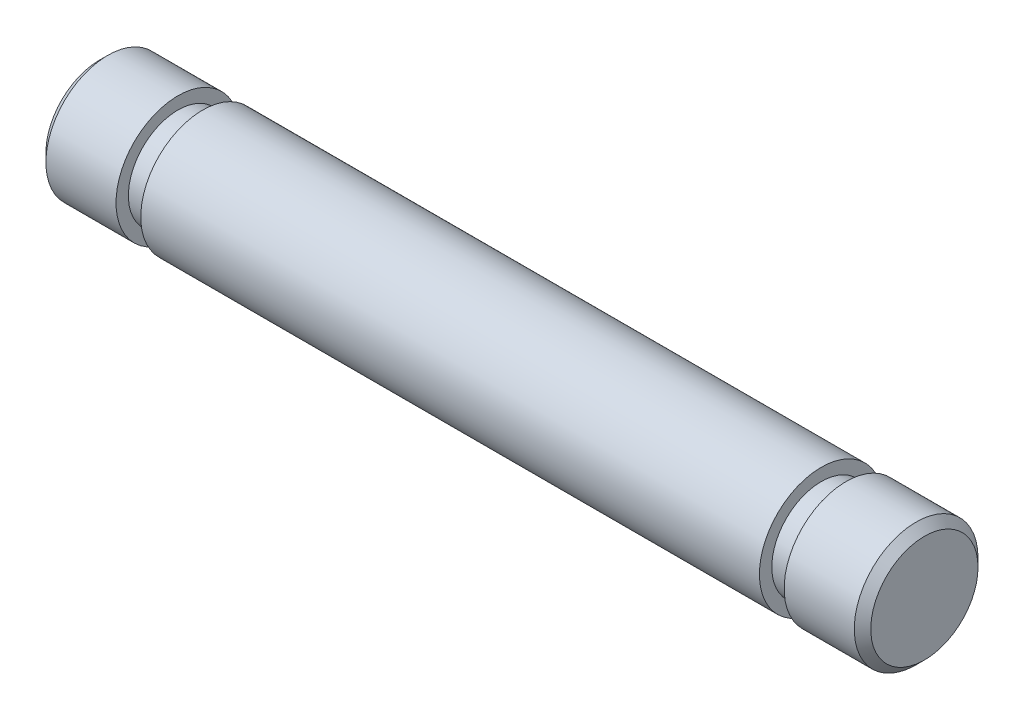
from build123d import *

# Parameters (mm, degrees)
SKETCH_2_R          = 1.5
EXTRUDE_1_DEPTH     = 10
CUT_EXTRUDE_START   = -7.5
SKETCH_3_R          = 1.5
SKETCH_3_R_2        = 1.2
CUT_EXTRUDE_1_DEPTH = 0.6
CHAMFER_1_SIZE      = 0.2


with BuildPart() as part:
    # 草图2 → 凸台-拉伸1 (new body, symmetric)
    with BuildSketch(Plane(origin=(0, 0, 0), x_dir=(0, 0, -1), z_dir=(1, 0, 0))):
        Circle(SKETCH_2_R)
    extrude(amount=EXTRUDE_1_DEPTH, both=True)

    # 草图3 → 切除-拉伸1 (cut)
    with BuildSketch(Plane(origin=(0, 0, 0), x_dir=(0, 0, -1), z_dir=(1, 0, 0)).offset(CUT_EXTRUDE_START)):
        Circle(SKETCH_3_R)
        Circle(SKETCH_3_R_2, mode=Mode.SUBTRACT)
    cut_extrude_1 = extrude(amount=-CUT_EXTRUDE_1_DEPTH, mode=Mode.SUBTRACT)

    # 镜向1: 切除-拉伸1 across plane
    add(cut_extrude_1.mirror(Plane(origin=(0, 0, 0), x_dir=(0, 0, 1), z_dir=(1, 0, 0))), mode=Mode.SUBTRACT)

    # 倒角1
    chamfer_1_edges = [part.edges().sort_by_distance(p)[0] for p in [
        (-10, 0, 1.5),
        (10, 0, 1.5),
    ]]
    chamfer(chamfer_1_edges, length=CHAMFER_1_SIZE)


solid = part.part
